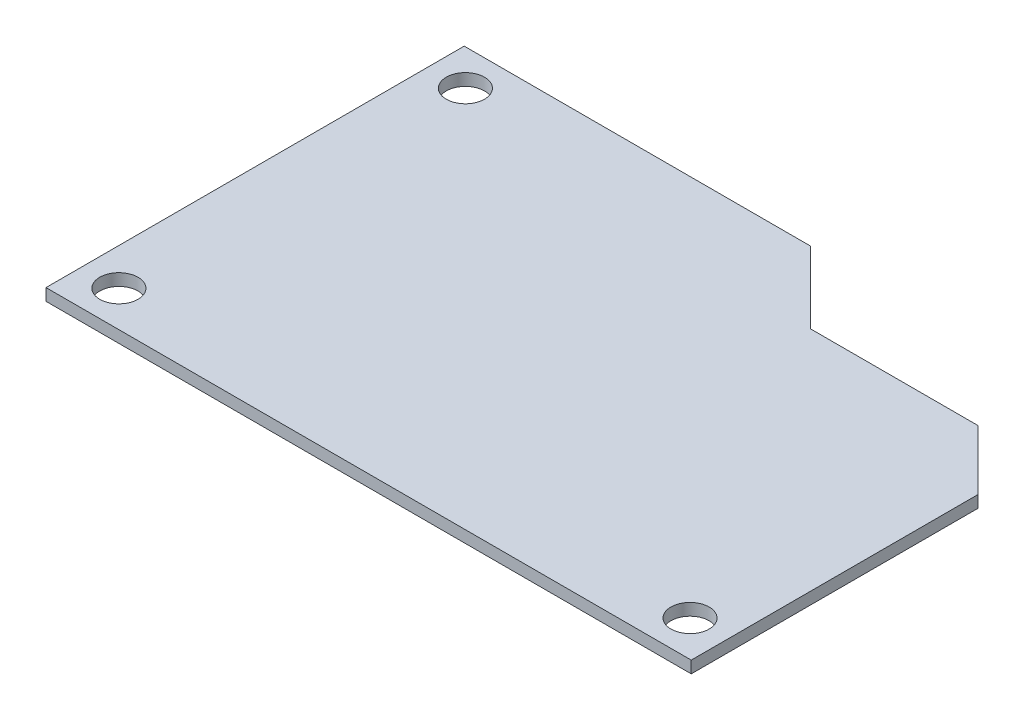
from build123d import *

# Parameters (mm, degrees)
SKETCH_1_W          = 54
SKETCH_1_H          = 35
EXTRUDE_1_DEPTH     = 1
CUT_EXTRUDE_1_DEPTH = 1
SKETCH_3_R          = 1.6
CUT_EXTRUDE_2_DEPTH = 1


with BuildPart() as part:
    # Эскиз1 → Бобышка-Вытянуть1 (new body)
    with BuildSketch(Plane(origin=(0, 0, 0), x_dir=(1, 0, 0), z_dir=(0, 1, 0))):
        Rectangle(SKETCH_1_W, SKETCH_1_H)
    extrude(amount=EXTRUDE_1_DEPTH)

    # Эскиз2 → Вырез-Вытянуть1 (cut)
    with BuildSketch(Plane(origin=(0, 1, 0), x_dir=(1, 0, 0), z_dir=(0, 1, 0))):
        Polygon((2, 17.5), (8, 11.5), (22, 11.5), (27, 6.5), (27, 17.5), align=None)
    extrude(amount=-CUT_EXTRUDE_1_DEPTH, mode=Mode.SUBTRACT)

    # Эскиз3 → Вырез-Вытянуть2 (cut)
    with BuildSketch(Plane(origin=(0, 1, 0), x_dir=(1, 0, 0), z_dir=(0, 1, 0))):
        with Locations((-23.9, 14.5)):
            Circle(SKETCH_3_R)
        with Locations((-23.9, -14.5)):
            Circle(SKETCH_3_R)
        with Locations((23.9, -14.5)):
            Circle(SKETCH_3_R)
    extrude(amount=-CUT_EXTRUDE_2_DEPTH, mode=Mode.SUBTRACT)


solid = part.part
